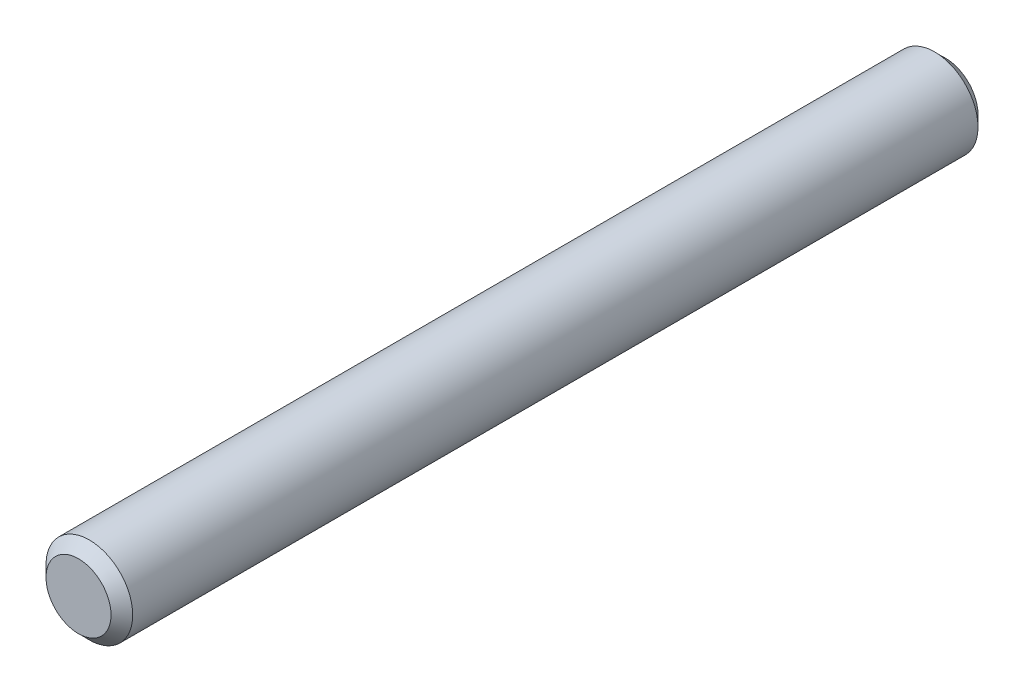
from build123d import *

# Parameters (mm, degrees)
ESQUISSE2_R      = 4
EXTRUSION1_DEPTH = 80
CHANFREIN1_SIZE  = 1


with BuildPart() as part:
    # Esquisse2 → Extrusion1 (new body)
    with BuildSketch(Plane.XY):
        Circle(ESQUISSE2_R)
    extrude(amount=EXTRUSION1_DEPTH)

    # Chanfrein1
    chanfrein1_edges = [part.edges().sort_by_distance(p)[0] for p in [
        (-4, 0, 0),
        (-4, 0, 80),
    ]]
    chamfer(chanfrein1_edges, length=CHANFREIN1_SIZE)


solid = part.part
